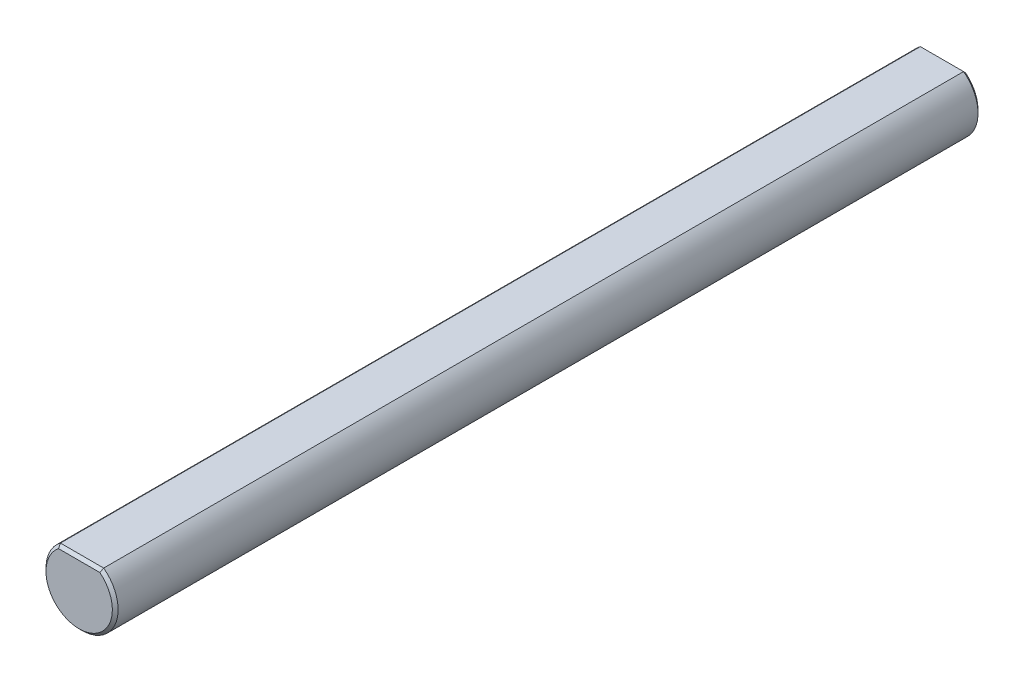
from build123d import *

# Parameters (mm, degrees)
BOSS_EXTRUDE1_DEPTH = 38.1
CHAMFER1_SIZE       = 0.254


with BuildPart() as part:
    # Sketch1 → Boss-Extrude1 (new body, symmetric)
    with BuildSketch(Plane.XY):
        with BuildLine():
            Line((1.905, 2.54), (-1.905, 2.54))
            ThreePointArc((-1.905, 2.54), (0, -3.175), (1.905, 2.54))
        make_face()
    extrude(amount=BOSS_EXTRUDE1_DEPTH, both=True)

    # Chamfer1
    chamfer1_edges = [part.edges().sort_by_distance(p)[0] for p in [
        (0, 2.54, -38.1),
        (0, -3.175, -38.1),
        (0, -3.175, 38.1),
        (0, 2.54, 38.1),
    ]]
    chamfer(chamfer1_edges, length=CHAMFER1_SIZE)


solid = part.part
